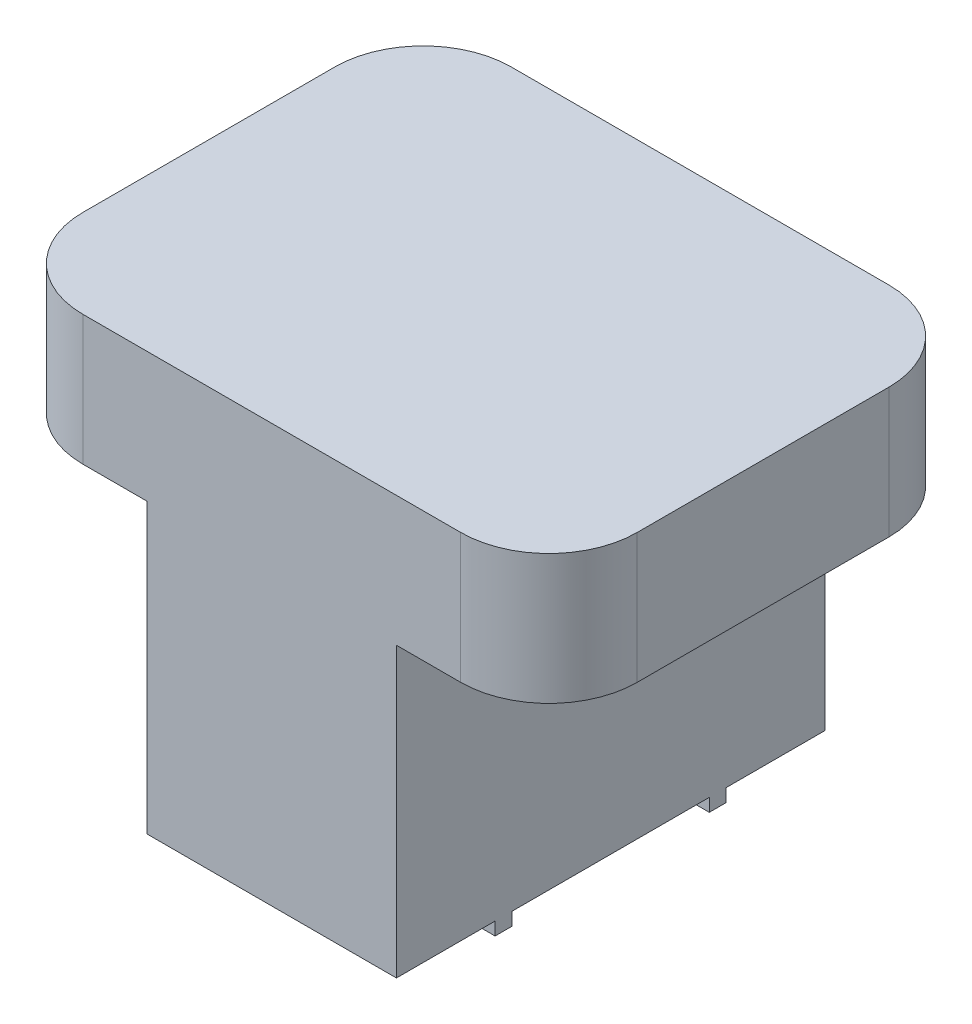
from build123d import *

# Parameters (mm, degrees)
BASE_EXTRUDE_DEPTH  = 20.447
CUT_EXTRUDE1_DEPTH  = 28.194
SKETCH3_W           = 5.4864
SKETCH3_H           = 1.651
BOSS_EXTRUDE1_DEPTH = 1.27


with BuildPart() as part:
    # Sketch1 → Base-Extrude (new, symmetric)
    with BuildSketch(Plane(origin=(0, 0, 0), x_dir=(1, 0, 0), z_dir=(0, 1, 0))):
        with BuildLine():
            Line((-18.4785, 20.955), (18.4785, 20.955))
            ThreePointArc((18.4785, 20.955), (24.585074162, 18.425574162), (27.1145, 12.319))
            Line((27.1145, 12.319), (27.1145, -12.319))
            ThreePointArc((27.1145, -12.319), (24.585074162, -18.425574162), (18.4785, -20.955))
            Line((18.4785, -20.955), (-18.4785, -20.955))
            ThreePointArc((-18.4785, -20.955), (-24.585074162, -18.425574162), (-27.1145, -12.319))
            Line((-27.1145, -12.319), (-27.1145, 12.319))
            ThreePointArc((-27.1145, 12.319), (-24.585074162, 18.425574162), (-18.4785, 20.955))
        make_face()
    extrude(amount=BASE_EXTRUDE_DEPTH, both=True)

    # Sketch2 → Cut-Extrude1 (cut)
    with BuildSketch(Plane.XZ.offset(20.447)):
        with BuildLine():
            Line((12.192, 20.955), (12.192, -20.955))
            Line((12.192, -20.955), (18.4785, -20.955))
            ThreePointArc((18.4785, -20.955), (24.585074162, -18.425574162), (27.1145, -12.319))
            Line((27.1145, -12.319), (27.1145, 12.319))
            ThreePointArc((27.1145, 12.319), (24.585074162, 18.425574162), (18.4785, 20.955))
            Line((18.4785, 20.955), (12.192, 20.955))
        make_face()
        with BuildLine():
            Line((-18.4785, -20.955), (-12.192, -20.955))
            Line((-12.192, -20.955), (-12.192, 20.955))
            Line((-12.192, 20.955), (-18.4785, 20.955))
            ThreePointArc((-18.4785, 20.955), (-24.585074162, 18.425574162), (-27.1145, 12.319))
            Line((-27.1145, 12.319), (-27.1145, -12.319))
            ThreePointArc((-27.1145, -12.319), (-24.585074162, -18.425574162), (-18.4785, -20.955))
        make_face()
    extrude(amount=-CUT_EXTRUDE1_DEPTH, mode=Mode.SUBTRACT)

    # Sketch3 → Boss-Extrude1 (add)
    with BuildSketch(Plane.XZ.offset(20.447)):
        with Locations((9.4488, -10.4775)):
            Rectangle(SKETCH3_W, SKETCH3_H)
        with Locations((9.4488, 10.4775)):
            Rectangle(SKETCH3_W, SKETCH3_H)
        with Locations((-9.4488, 10.4775)):
            Rectangle(SKETCH3_W, SKETCH3_H)
        with Locations((-9.4488, -10.4775)):
            Rectangle(SKETCH3_W, SKETCH3_H)
    extrude(amount=BOSS_EXTRUDE1_DEPTH)


solid = part.part
